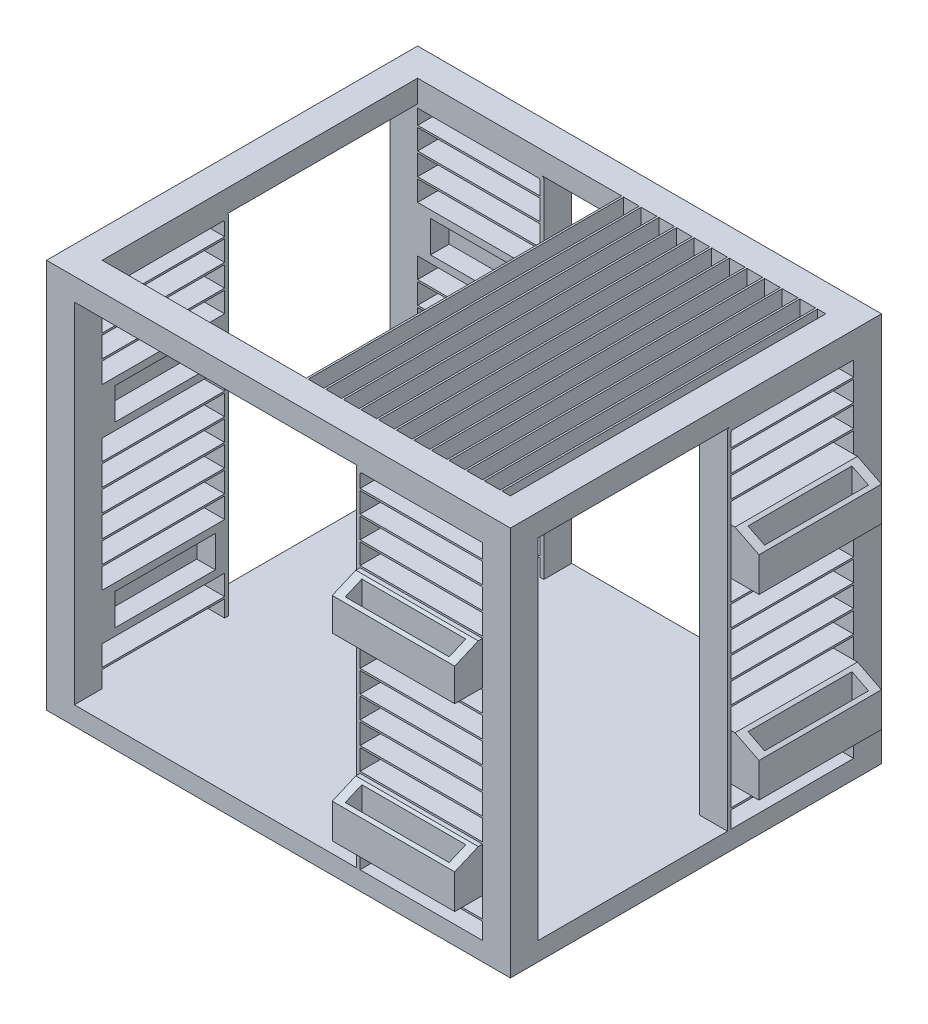
from build123d import *

# Parameters (mm, degrees)
SKETCH2_W            = 2500
SKETCH2_H            = 2000
BOSS_EXTRUDE1_DEPTH  = 100
SKETCH3_W            = 150
SKETCH3_H            = 150
BOSS_EXTRUDE3_DEPTH  = 2000
SKETCH6_W            = 20
SKETCH6_H            = 150
SKETCH6_W_2          = 150
SKETCH6_H_2          = 20
BOSS_EXTRUDE4_DEPTH  = 1880
SKETCH7_W            = 680
SKETCH7_H            = 23.335821076
BOSS_EXTRUDE5_DEPTH  = 150
FILLET2_R            = 10
SKETCH8_W            = 680
SKETCH8_H            = 20
BOSS_EXTRUDE6_DEPTH  = 150
FILLET3_R            = 10
SKETCH9_W            = 830
SKETCH9_H            = 20
BOSS_EXTRUDE7_DEPTH  = 150
FILLET4_R            = 10
SKETCH10_W           = 830
SKETCH10_H           = 23.335821076
BOSS_EXTRUDE8_DEPTH  = 150
FILLET5_R            = 10
SKETCH11_W           = 150
SKETCH11_H           = 1700
SKETCH11_W_2         = 2200
SKETCH11_H_2         = 150
BOSS_EXTRUDE11_DEPTH = 120
SKETCH12_W           = 150
SKETCH12_H           = 10
BOSS_EXTRUDE12_DEPTH = 660
SKETCH14_W           = 150
SKETCH14_H           = 10
BOSS_EXTRUDE13_DEPTH = 660
SKETCH15_W           = 150
SKETCH15_H           = 10
BOSS_EXTRUDE14_DEPTH = 660
SKETCH16_W           = 150
SKETCH16_H           = 10
BOSS_EXTRUDE15_DEPTH = 660
SKETCH17_W           = 660
SKETCH17_H           = 250
BOSS_EXTRUDE21_DEPTH = 150
SKETCH18_W           = 660
SKETCH18_H           = 230
SKETCH18_H_2         = 240
BOSS_EXTRUDE23_DEPTH = 150
SKETCH19_W           = 660
SKETCH19_H           = 250
BOSS_EXTRUDE24_DEPTH = 150
SKETCH20_W           = 660
SKETCH20_H           = 250
BOSS_EXTRUDE25_DEPTH = 150
SKETCH22_W           = 527.870675706
SKETCH22_H           = 170
CUT_EXTRUDE2_DEPTH   = 2300
SKETCH23_W           = 540
SKETCH23_H           = 170
CUT_EXTRUDE3_DEPTH   = 100
SKETCH24_W           = 540
SKETCH24_H           = 170
CUT_EXTRUDE4_DEPTH   = 100
SKETCH25_W           = 540
SKETCH25_H           = 170
CUT_EXTRUDE5_DEPTH   = 100
CUT_EXTRUDE8_DEPTH   = 2151
CUT_EXTRUDE9_DEPTH   = 2651
SKETCH30_W           = 89.458996963
SKETCH30_H           = 560
SKETCH30_W_2         = 560
SKETCH30_H_2         = 89.458996963
CUT_EXTRUDE10_DEPTH  = 800
SKETCH31_W           = 560
SKETCH31_H           = 89.458996963
SKETCH31_W_2         = 89.458996963
SKETCH31_H_2         = 560
BOSS_EXTRUDE26_DEPTH = 30
SKETCH33_W           = 10
SKETCH33_H           = 120
BOSS_EXTRUDE27_DEPTH = 1700


with BuildPart() as part:
    # Sketch2 → Boss-Extrude1 (new body)
    with BuildSketch(Plane(origin=(0, 0, 0), x_dir=(1, 0, 0), z_dir=(0, 1, 0))):
        Rectangle(SKETCH2_W, SKETCH2_H)
    extrude(amount=BOSS_EXTRUDE1_DEPTH)

    # Sketch3 → Boss-Extrude3 (add)
    with BuildSketch(Plane(origin=(0, 100, 0), x_dir=(1, 0, 0), z_dir=(0, 1, 0))):
        with Locations((-1175, -925)):
            Rectangle(SKETCH3_W, SKETCH3_H)
        with Locations((-1175, 925)):
            Rectangle(SKETCH3_W, SKETCH3_H)
        with Locations((1175, 925)):
            Rectangle(SKETCH3_W, SKETCH3_H)
        with Locations((1175, -925)):
            Rectangle(SKETCH3_W, SKETCH3_H)
    extrude(amount=BOSS_EXTRUDE3_DEPTH)

    # Sketch6 → Boss-Extrude4 (add)
    with BuildSketch(Plane(origin=(0, 100, 0), x_dir=(1, 0, 0), z_dir=(0, 1, 0))):
        with Locations((430, -925)):
            Rectangle(SKETCH6_W, SKETCH6_H)
        with Locations((-430, 925)):
            Rectangle(SKETCH6_W, SKETCH6_H)
        with Locations((1175, 180)):
            Rectangle(SKETCH6_W_2, SKETCH6_H_2)
        with Locations((-1175, -180)):
            Rectangle(SKETCH6_W_2, SKETCH6_H_2)
    extrude(amount=BOSS_EXTRUDE4_DEPTH)

    # Sketch7 → Boss-Extrude5 (add)
    with BuildSketch(Plane.XY.offset(1000)):
        with Locations((760, 1968.332089462)):
            Rectangle(SKETCH7_W, SKETCH7_H)
    extrude(amount=-BOSS_EXTRUDE5_DEPTH)

    # Fillet2
    fillet2_edges = [part.edges().sort_by_distance(p)[0] for p in [
        (440, 1956.664178924, 925),
        (420, 1980, 925),
    ]]
    fillet(fillet2_edges, radius=FILLET2_R)

    # Sketch8 → Boss-Extrude6 (add)
    with BuildSketch(Plane(origin=(1250, 0, 0), x_dir=(0, 0, -1), z_dir=(1, 0, 0))):
        with Locations((510, 1970)):
            Rectangle(SKETCH8_W, SKETCH8_H)
    extrude(amount=-BOSS_EXTRUDE6_DEPTH)

    # Fillet3
    fillet3_edges = [part.edges().sort_by_distance(p)[0] for p in [
        (1175, 1960, -190),
        (1175, 1980, -170),
    ]]
    fillet(fillet3_edges, radius=FILLET3_R)

    # Sketch9 → Boss-Extrude7 (add)
    with BuildSketch(Plane(origin=(0, 0, -1000), x_dir=(-1, 0, 0), z_dir=(0, 0, -1))):
        with Locations((835, 1970)):
            Rectangle(SKETCH9_W, SKETCH9_H)
    extrude(amount=-BOSS_EXTRUDE7_DEPTH)

    # Fillet4
    fillet4_edges = [part.edges().sort_by_distance(p)[0] for p in [
        (-440, 1960, -925),
        (-420, 1980, -925),
    ]]
    fillet(fillet4_edges, radius=FILLET4_R)

    # Sketch10 → Boss-Extrude8 (add)
    with BuildSketch(Plane.ZY.offset(1250)):
        with Locations((585, 1968.332089462)):
            Rectangle(SKETCH10_W, SKETCH10_H)
    extrude(amount=-BOSS_EXTRUDE8_DEPTH)

    # Fillet5
    fillet5_edges = [part.edges().sort_by_distance(p)[0] for p in [
        (-1175, 1956.664178924, 190),
        (-1175, 1980, 170),
    ]]
    fillet(fillet5_edges, radius=FILLET5_R)

    # Sketch11 → Boss-Extrude11 (add)
    with BuildSketch(Plane(origin=(0, 2100, 0), x_dir=(1, 0, 0), z_dir=(0, 1, 0))):
        with Locations((-1175, 0)):
            Rectangle(SKETCH11_W, SKETCH11_H)
        with Locations((0, -925)):
            Rectangle(SKETCH11_W_2, SKETCH11_H_2)
        with Locations((1175, 0)):
            Rectangle(SKETCH11_W, SKETCH11_H)
        with Locations((0, 925)):
            Rectangle(SKETCH11_W_2, SKETCH11_H_2)
    extrude(amount=-BOSS_EXTRUDE11_DEPTH)

    # Sketch12 → Boss-Extrude12 (add)
    with BuildSketch(Plane.XY.offset(190)):
        with Locations((-1175, 1875)):
            Rectangle(SKETCH12_W, SKETCH12_H)
        with Locations((-1175, 1755)):
            Rectangle(SKETCH12_W, SKETCH12_H)
        with Locations((-1175, 1635)):
            Rectangle(SKETCH12_W, SKETCH12_H)
        with Locations((-1175, 1515)):
            Rectangle(SKETCH12_W, SKETCH12_H)
        with Locations((-1175, 1395)):
            Rectangle(SKETCH12_W, SKETCH12_H)
        with Locations((-1175, 1275)):
            Rectangle(SKETCH12_W, SKETCH12_H)
        with Locations((-1175, 1155)):
            Rectangle(SKETCH12_W, SKETCH12_H)
        with Locations((-1175, 1035)):
            Rectangle(SKETCH12_W, SKETCH12_H)
        with Locations((-1175, 915)):
            Rectangle(SKETCH12_W, SKETCH12_H)
        with Locations((-1175, 795)):
            Rectangle(SKETCH12_W, SKETCH12_H)
        with Locations((-1175, 675)):
            Rectangle(SKETCH12_W, SKETCH12_H)
        with Locations((-1175, 555)):
            Rectangle(SKETCH12_W, SKETCH12_H)
        with Locations((-1175, 435)):
            Rectangle(SKETCH12_W, SKETCH12_H)
        with Locations((-1175, 315)):
            Rectangle(SKETCH12_W, SKETCH12_H)
        with Locations((-1175, 195)):
            Rectangle(SKETCH12_W, SKETCH12_H)
    extrude(amount=BOSS_EXTRUDE12_DEPTH)

    # Sketch14 → Boss-Extrude13 (add)
    with BuildSketch(Plane(origin=(440, 0, 0), x_dir=(0, 0, -1), z_dir=(1, 0, 0))):
        with Locations((-925, 1875)):
            Rectangle(SKETCH14_W, SKETCH14_H)
        with Locations((-925, 1755)):
            Rectangle(SKETCH14_W, SKETCH14_H)
        with Locations((-925, 1635)):
            Rectangle(SKETCH14_W, SKETCH14_H)
        with Locations((-925, 1515)):
            Rectangle(SKETCH14_W, SKETCH14_H)
        with Locations((-925, 1395)):
            Rectangle(SKETCH14_W, SKETCH14_H)
        with Locations((-925, 1275)):
            Rectangle(SKETCH14_W, SKETCH14_H)
        with Locations((-925, 1155)):
            Rectangle(SKETCH14_W, SKETCH14_H)
        with Locations((-925, 1035)):
            Rectangle(SKETCH14_W, SKETCH14_H)
        with Locations((-925, 915)):
            Rectangle(SKETCH14_W, SKETCH14_H)
        with Locations((-925, 795)):
            Rectangle(SKETCH14_W, SKETCH14_H)
        with Locations((-925, 675)):
            Rectangle(SKETCH14_W, SKETCH14_H)
        with Locations((-925, 555)):
            Rectangle(SKETCH14_W, SKETCH14_H)
        with Locations((-925, 435)):
            Rectangle(SKETCH14_W, SKETCH14_H)
        with Locations((-925, 315)):
            Rectangle(SKETCH14_W, SKETCH14_H)
        with Locations((-925, 195)):
            Rectangle(SKETCH14_W, SKETCH14_H)
    extrude(amount=BOSS_EXTRUDE13_DEPTH)

    # Sketch15 → Boss-Extrude14 (add)
    with BuildSketch(Plane(origin=(0, 0, -190), x_dir=(-1, 0, 0), z_dir=(0, 0, -1))):
        with Locations((-1175, 1875)):
            Rectangle(SKETCH15_W, SKETCH15_H)
        with Locations((-1175, 1755)):
            Rectangle(SKETCH15_W, SKETCH15_H)
        with Locations((-1175, 1635)):
            Rectangle(SKETCH15_W, SKETCH15_H)
        with Locations((-1175, 1515)):
            Rectangle(SKETCH15_W, SKETCH15_H)
        with Locations((-1175, 1395)):
            Rectangle(SKETCH15_W, SKETCH15_H)
        with Locations((-1175, 1275)):
            Rectangle(SKETCH15_W, SKETCH15_H)
        with Locations((-1175, 1155)):
            Rectangle(SKETCH15_W, SKETCH15_H)
        with Locations((-1175, 1035)):
            Rectangle(SKETCH15_W, SKETCH15_H)
        with Locations((-1175, 915)):
            Rectangle(SKETCH15_W, SKETCH15_H)
        with Locations((-1175, 795)):
            Rectangle(SKETCH15_W, SKETCH15_H)
        with Locations((-1175, 675)):
            Rectangle(SKETCH15_W, SKETCH15_H)
        with Locations((-1175, 555)):
            Rectangle(SKETCH15_W, SKETCH15_H)
        with Locations((-1175, 435)):
            Rectangle(SKETCH15_W, SKETCH15_H)
        with Locations((-1175, 315)):
            Rectangle(SKETCH15_W, SKETCH15_H)
        with Locations((-1175, 195)):
            Rectangle(SKETCH15_W, SKETCH15_H)
    extrude(amount=BOSS_EXTRUDE14_DEPTH)

    # Sketch16 → Boss-Extrude15 (add)
    with BuildSketch(Plane.ZY.offset(440)):
        with Locations((-925, 1875)):
            Rectangle(SKETCH16_W, SKETCH16_H)
        with Locations((-925, 1755)):
            Rectangle(SKETCH16_W, SKETCH16_H)
        with Locations((-925, 1635)):
            Rectangle(SKETCH16_W, SKETCH16_H)
        with Locations((-925, 1515)):
            Rectangle(SKETCH16_W, SKETCH16_H)
        with Locations((-925, 1395)):
            Rectangle(SKETCH16_W, SKETCH16_H)
        with Locations((-925, 1275)):
            Rectangle(SKETCH16_W, SKETCH16_H)
        with Locations((-925, 1155)):
            Rectangle(SKETCH16_W, SKETCH16_H)
        with Locations((-925, 1035)):
            Rectangle(SKETCH16_W, SKETCH16_H)
        with Locations((-925, 915)):
            Rectangle(SKETCH16_W, SKETCH16_H)
        with Locations((-925, 795)):
            Rectangle(SKETCH16_W, SKETCH16_H)
        with Locations((-925, 675)):
            Rectangle(SKETCH16_W, SKETCH16_H)
        with Locations((-925, 555)):
            Rectangle(SKETCH16_W, SKETCH16_H)
        with Locations((-925, 435)):
            Rectangle(SKETCH16_W, SKETCH16_H)
        with Locations((-925, 315)):
            Rectangle(SKETCH16_W, SKETCH16_H)
        with Locations((-925, 195)):
            Rectangle(SKETCH16_W, SKETCH16_H)
    extrude(amount=BOSS_EXTRUDE15_DEPTH)

    # Sketch17 → Boss-Extrude21 (add, symmetric)
    with BuildSketch(Plane.ZY.offset(1250)):
        with Locations((520, 435)):
            Rectangle(SKETCH17_W, SKETCH17_H)
        with Locations((520, 1395)):
            Rectangle(SKETCH17_W, SKETCH17_H)
    extrude(amount=BOSS_EXTRUDE21_DEPTH, both=True)

    # Sketch18 → Boss-Extrude23 (add, symmetric)
    with BuildSketch(Plane.XY.offset(1000)):
        with Locations((770, 1395)):
            Rectangle(SKETCH18_W, SKETCH18_H)
        with Locations((770, 430)):
            Rectangle(SKETCH18_W, SKETCH18_H_2)
    extrude(amount=BOSS_EXTRUDE23_DEPTH, both=True)

    # Sketch19 → Boss-Extrude24 (add, symmetric)
    with BuildSketch(Plane(origin=(1250, 0, 0), x_dir=(0, 0, -1), z_dir=(1, 0, 0))):
        with Locations((520, 1395)):
            Rectangle(SKETCH19_W, SKETCH19_H)
        with Locations((520, 435)):
            Rectangle(SKETCH19_W, SKETCH19_H)
    extrude(amount=BOSS_EXTRUDE24_DEPTH, both=True)

    # Sketch20 → Boss-Extrude25 (add, symmetric)
    with BuildSketch(Plane(origin=(0, 0, -1000), x_dir=(-1, 0, 0), z_dir=(0, 0, -1))):
        with Locations((770, 1395)):
            Rectangle(SKETCH20_W, SKETCH20_H)
        with Locations((770, 435)):
            Rectangle(SKETCH20_W, SKETCH20_H)
    extrude(amount=BOSS_EXTRUDE25_DEPTH, both=True)

    # Sketch22 → Cut-Extrude2 (cut)
    with BuildSketch(Plane(origin=(-1100, 0, 0), x_dir=(0, 0, -1), z_dir=(1, 0, 0))):
        with Locations((519.991080653, 1395)):
            Rectangle(SKETCH22_W, SKETCH22_H)
        with Locations((516.064662147, 435)):
            Rectangle(SKETCH22_W, SKETCH22_H)
    extrude(amount=CUT_EXTRUDE2_DEPTH, mode=Mode.SUBTRACT)

    # Sketch23 → Cut-Extrude3 (cut)
    with BuildSketch(Plane.XY.offset(-850)):
        with Locations((-760, 1395)):
            Rectangle(SKETCH23_W, SKETCH23_H)
        with Locations((-760, 435)):
            Rectangle(SKETCH23_W, SKETCH23_H)
    extrude(amount=-CUT_EXTRUDE3_DEPTH, mode=Mode.SUBTRACT)

    # Sketch24 → Cut-Extrude4 (cut)
    with BuildSketch(Plane(origin=(-1100, 0, 0), x_dir=(0, 0, -1), z_dir=(1, 0, 0))):
        with Locations((-510, 1395)):
            Rectangle(SKETCH24_W, SKETCH24_H)
        with Locations((-510, 435)):
            Rectangle(SKETCH24_W, SKETCH24_H)
    extrude(amount=-CUT_EXTRUDE4_DEPTH, mode=Mode.SUBTRACT)

    # Sketch25 → Cut-Extrude5 (cut)
    with BuildSketch(Plane(origin=(0, 0, 850), x_dir=(-1, 0, 0), z_dir=(0, 0, -1))):
        with Locations((-760, 1395)):
            Rectangle(SKETCH25_W, SKETCH25_H)
        with Locations((-760, 435)):
            Rectangle(SKETCH25_W, SKETCH25_H)
    extrude(amount=-CUT_EXTRUDE5_DEPTH, mode=Mode.SUBTRACT)

    # Sketch26 → Cut-Extrude8 (cut, through all)
    with BuildSketch(Plane.XY.offset(1000)):
        Polygon((-1270.541003037, 1520), (-1400, 1455.326430012), (-1400, 1520), align=None)
        Polygon((-1270.541003037, 560), (-1400, 495.326430012), (-1400, 560), align=None)
        Polygon((1400, 1455.326430012), (1400, 1520), (1270.541003037, 1520), align=None)
        Polygon((1400, 495.326430012), (1400, 560), (1270.541003037, 560), align=None)
    extrude(amount=-CUT_EXTRUDE8_DEPTH, mode=Mode.SUBTRACT)

    # Sketch29 → Cut-Extrude9 (cut, through all)
    with BuildSketch(Plane(origin=(1250, 0, 0), x_dir=(0, 0, -1), z_dir=(1, 0, 0))):
        Polygon((1150, 1455.326430012), (1000, 1520), (1150, 1520), align=None)
        Polygon((1000, 560), (1150, 495.326430012), (1150, 560), align=None)
        Polygon((-1000, 560), (-1150, 495.326430012), (-1150, 560), align=None)
        Polygon((-1150, 1520), (-1150, 1455.326430012), (-1000, 1520), align=None)
    extrude(amount=-CUT_EXTRUDE9_DEPTH, mode=Mode.SUBTRACT)

    # Sketch30 → Cut-Extrude10 (cut)
    with BuildSketch(Plane(origin=(0, 2100, 0), x_dir=(1, 0, 0), z_dir=(0, 1, 0))):
        with Locations((-1335.270501519, -520)):
            Rectangle(SKETCH30_W, SKETCH30_H)
        with Locations((770, -1085.270501519)):
            Rectangle(SKETCH30_W_2, SKETCH30_H_2)
        with Locations((1335.270501519, 520)):
            Rectangle(SKETCH30_W, SKETCH30_H)
        with Locations((-770, 1085.270501519)):
            Rectangle(SKETCH30_W_2, SKETCH30_H_2)
    cut_extrude10 = extrude(amount=-CUT_EXTRUDE10_DEPTH, mode=Mode.SUBTRACT)

    # Mirror10: Cut-Extrude10 across plane
    add(cut_extrude10.mirror(Plane.ZX.offset(1040)), mode=Mode.SUBTRACT)

    # Sketch31 → Boss-Extrude26 (add)
    with BuildSketch(Plane.XZ.offset(-310)):
        with Locations((770, 1085.270501519)):
            Rectangle(SKETCH31_W, SKETCH31_H)
        with Locations((1335.270501519, -520)):
            Rectangle(SKETCH31_W_2, SKETCH31_H_2)
        with Locations((-770, -1085.270501519)):
            Rectangle(SKETCH31_W, SKETCH31_H)
        with Locations((-1335.270501519, 520)):
            Rectangle(SKETCH31_W_2, SKETCH31_H_2)
    extrude(amount=-BOSS_EXTRUDE26_DEPTH)

    # Sketch33 → Boss-Extrude27 (add)
    with BuildSketch(Plane.XY.offset(-850)):
        with Locations((5, 2040)):
            Rectangle(SKETCH33_W, SKETCH33_H)
        with Locations((100, 2040)):
            Rectangle(SKETCH33_W, SKETCH33_H)
        with Locations((195, 2040)):
            Rectangle(SKETCH33_W, SKETCH33_H)
        with Locations((290, 2040)):
            Rectangle(SKETCH33_W, SKETCH33_H)
        with Locations((385, 2040)):
            Rectangle(SKETCH33_W, SKETCH33_H)
        with Locations((480, 2040)):
            Rectangle(SKETCH33_W, SKETCH33_H)
        with Locations((575, 2040)):
            Rectangle(SKETCH33_W, SKETCH33_H)
        with Locations((670, 2040)):
            Rectangle(SKETCH33_W, SKETCH33_H)
        with Locations((765, 2040)):
            Rectangle(SKETCH33_W, SKETCH33_H)
        with Locations((860, 2040)):
            Rectangle(SKETCH33_W, SKETCH33_H)
        with Locations((955, 2040)):
            Rectangle(SKETCH33_W, SKETCH33_H)
        with Locations((1050, 2040)):
            Rectangle(SKETCH33_W, SKETCH33_H)
    extrude(amount=BOSS_EXTRUDE27_DEPTH)


solid = part.part
